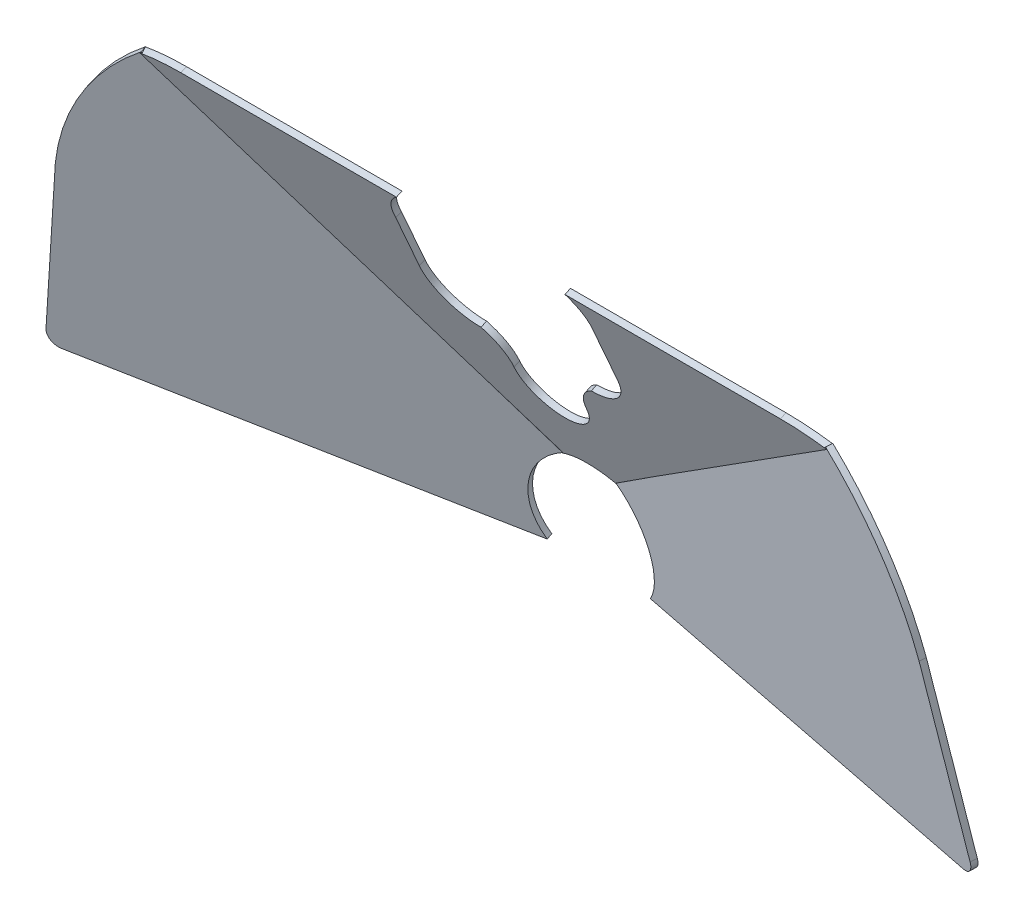
from build123d import *

# Parameters (mm, degrees)
BOSS_EXTRUDE1_DEPTH = 2.54
BOSS_EXTRUDE2_DEPTH = 2.54


with BuildPart() as part:
    # Sketch1 → Boss-Extrude1 (new body)
    with BuildSketch(Plane(origin=(0, -403.215393304, 914.186019304), x_dir=(1, 0, 0), z_dir=(0, -0.403554778, 0.914955486))):
        with BuildLine():
            Line((41.090457211, 1205.302750155), (41.090457211, 1181.172750155))
            add(Edge.make_bspline(
                [(41.090457211, 1181.172750155), (41.090457211, 1179.500406586), (40.786106444, 1177.855480514), (40.627250629, 1176.996911717), (40.38674257, 1176.156490093), (40.140401941, 1175.295687376), (39.810465838, 1174.462215303), (39.474066056, 1173.612414933), (39.053823577, 1172.79959973), (38.627425101, 1171.974877856), (38.118810853, 1171.196866161), (37.605369582, 1170.411470717), (37.013273567, 1169.682127132), (36.418695318, 1168.949725934), (35.750879918, 1168.281870238), (35.083841269, 1167.614791339), (34.350623023, 1167.019476589), (33.622163357, 1166.428025426), (32.835883994, 1165.913939303), (32.058807597, 1165.405870274), (31.233150426, 1164.978926578), (30.421305456, 1164.559125111), (29.570534852, 1164.222284318), (28.738051446, 1163.892683872), (27.876260062, 1163.646007586), (27.036829788, 1163.40573187), (26.177269641, 1163.246643712), (24.532849383, 1162.942292945), (22.86, 1162.942292945)],
                knots=[0, 0, 0, 0.125, 0.125, 0.1875, 0.1875, 0.25, 0.25, 0.3125, 0.3125, 0.375, 0.375, 0.4375, 0.4375, 0.5, 0.5, 0.5625, 0.5625, 0.625, 0.625, 0.6875, 0.6875, 0.75, 0.75, 0.8125, 0.8125, 0.875, 0.875, 1, 1, 1], degree=2))
            ThreePointArc((22.86, 1162.942292945), (17.107545571, 1156.658209277), (15.02386871, 1148.397535561))
            ThreePointArc((15.02386871, 1148.397535561), (0, 1133.373666883), (-15.02386871, 1148.397535561))
            ThreePointArc((-15.02386871, 1148.397535561), (-17.107545571, 1156.658209277), (-22.86, 1162.942292945))
            add(Edge.make_bspline(
                [(-41.090457211, 1181.172750155), (-41.090457211, 1179.500406586), (-40.786106444, 1177.855480514), (-40.627250629, 1176.996911717), (-40.38674257, 1176.156490093), (-40.140401941, 1175.295687376), (-39.810465838, 1174.462215303), (-39.474066056, 1173.612414933), (-39.053823577, 1172.79959973), (-38.627425101, 1171.974877856), (-38.118810853, 1171.196866161), (-37.605369582, 1170.411470717), (-37.013273567, 1169.682127132), (-36.418695318, 1168.949725934), (-35.750879918, 1168.281870238), (-35.083841269, 1167.614791339), (-34.350623023, 1167.019476589), (-33.622163357, 1166.428025426), (-32.835883994, 1165.913939303), (-32.058807597, 1165.405870274), (-31.233150426, 1164.978926578), (-30.421305456, 1164.559125111), (-29.570534852, 1164.222284318), (-28.738051446, 1163.892683872), (-27.876260062, 1163.646007586), (-27.036829788, 1163.40573187), (-26.177269641, 1163.246643712), (-24.532849383, 1162.942292945), (-22.86, 1162.942292945)],
                knots=[0, 0, 0, 0.125, 0.125, 0.1875, 0.1875, 0.25, 0.25, 0.3125, 0.3125, 0.375, 0.375, 0.4375, 0.4375, 0.5, 0.5, 0.5625, 0.5625, 0.625, 0.625, 0.6875, 0.6875, 0.75, 0.75, 0.8125, 0.8125, 0.875, 0.875, 1, 1, 1], degree=2))
            Line((-41.090457211, 1181.172750155), (-41.090457211, 1205.302750155))
            ThreePointArc((-41.090457211, 1205.302750155), (-39.838195765, 1213.399088759), (-34.922129755, 1219.952801638))
            Line((-34.922129755, 1219.952801638), (-124.282704843, 1219.952801638))
            ThreePointArc((-124.282704843, 1219.952801638), (-133.452528355, 1219.261665344), (-142.415163066, 1217.203872436))
            Line((-142.415163066, 1217.203872436), (-11.602437283, 1107.542547866))
            ThreePointArc((-11.602437283, 1107.542547866), (0, 1110.539391573), (11.602437283, 1107.542547866))
            Line((11.602437283, 1107.542547866), (142.415163066, 1217.203872436))
            ThreePointArc((142.415163066, 1217.203872436), (133.452528355, 1219.261665344), (124.282704843, 1219.952801638))
            Line((124.282704843, 1219.952801638), (34.922129755, 1219.952801638))
            ThreePointArc((34.922129755, 1219.952801638), (39.838195765, 1213.399088759), (41.090457211, 1205.302750155))
        make_face()
    boss_extrude1 = extrude(amount=BOSS_EXTRUDE1_DEPTH)


with BuildPart() as body_2:
    # Sketch2 → Boss-Extrude2 (new body)
    with BuildSketch(Plane(origin=(250.456709511, -189.811186969, 1179.622087881), x_dir=(-0.978727634, -0.032622557, 0.202553664), z_dir=(-0.205163879, 0.155485551, -0.966298104))):
        with BuildLine():
            Line((438.824397172, 866.073971669), (451.606917208, 795.421913218))
            ThreePointArc((451.606917208, 795.421913218), (450.542773626, 791.265264069), (446.699876764, 789.356788913))
            Line((446.699876764, 789.356788913), (277.752918196, 780.24161181))
            ThreePointArc((277.752918196, 780.24161181), (281.389861334, 801.904197312), (267.155321643, 818.633597954))
            Line((267.155321643, 818.633597954), (400.876040527, 924.729024753))
            ThreePointArc((400.876040527, 924.729024753), (425.219058104, 898.875003324), (438.824397172, 866.073971669))
        make_face()
    boss_extrude2 = extrude(amount=BOSS_EXTRUDE2_DEPTH)


with BuildPart() as part_1:
    add(part.part)

    add(body_2.part)  # Mirror7 merges body 2
    # Mirror7: Boss-Extrude1, Boss-Extrude2 across plane
    add(boss_extrude1.mirror(Plane(origin=(0, 0, 0), x_dir=(0, 0, 1), z_dir=(1, 0, 0))))
    add(boss_extrude2.mirror(Plane(origin=(0, 0, 0), x_dir=(0, 0, 1), z_dir=(1, 0, 0))))


solid = part_1.part
